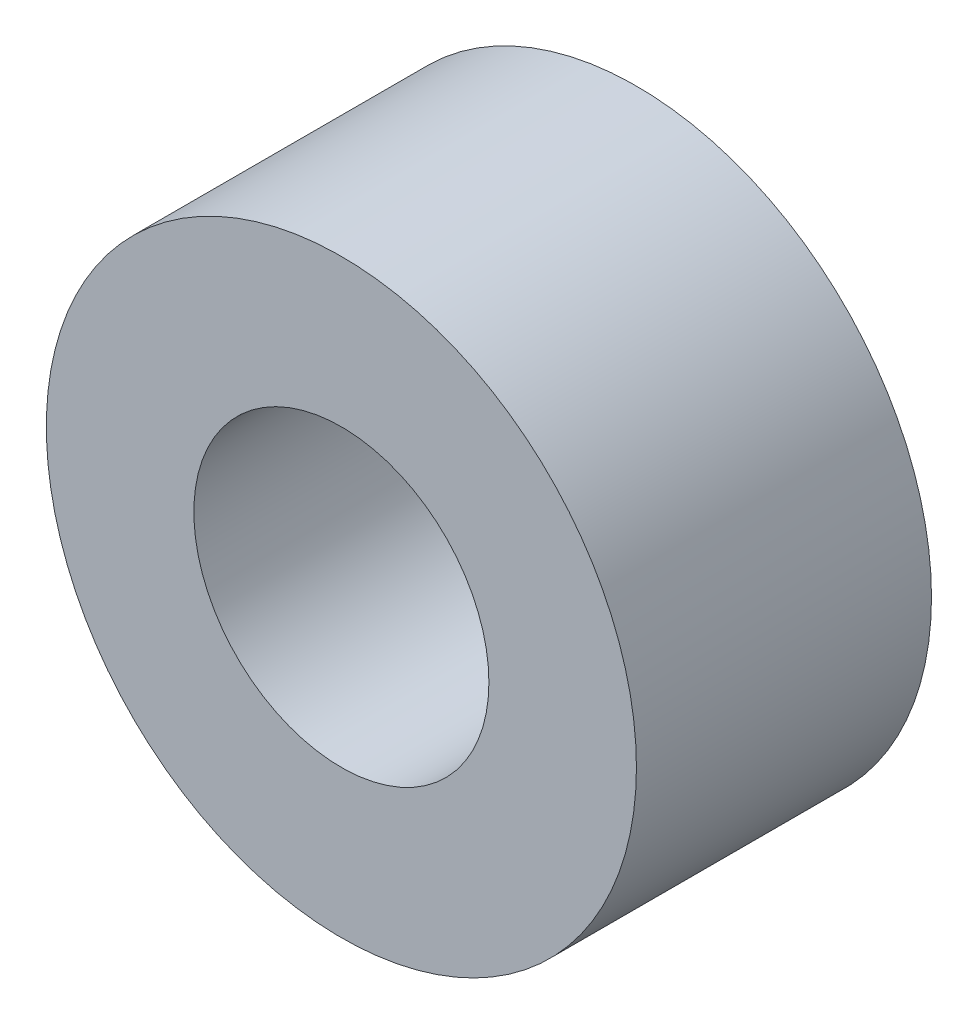
from build123d import *

# Parameters (mm, degrees)
ESQUISSE1_R        = 2
ESQUISSE1_R_2      = 1
BOSS_EXTRU_1_DEPTH = 2


with BuildPart() as part:
    # Esquisse1 → Boss.-Extru.1 (new body)
    with BuildSketch(Plane.XY):
        Circle(ESQUISSE1_R)
        Circle(ESQUISSE1_R_2, mode=Mode.SUBTRACT)
    extrude(amount=BOSS_EXTRU_1_DEPTH)


solid = part.part
